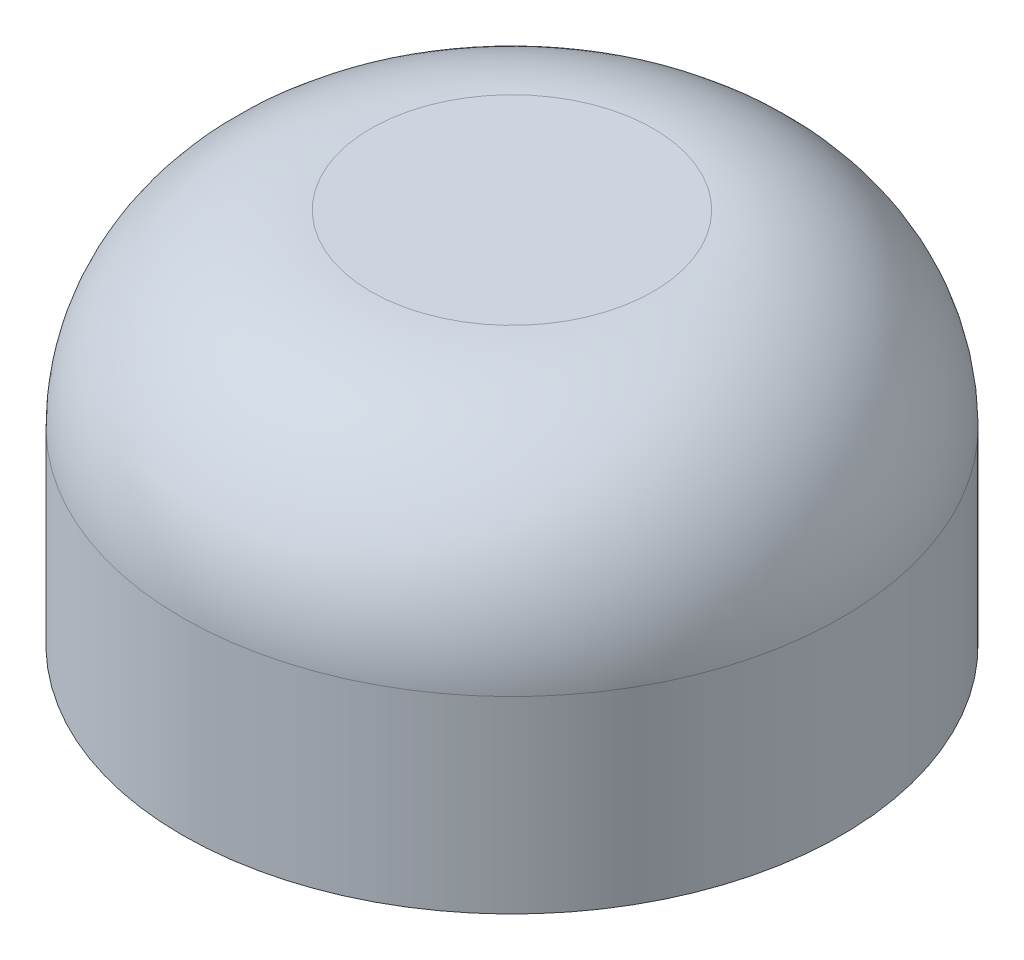
from build123d import *

# Parameters (mm, degrees)
SKETCH1_R           = 1.75
BOSS_EXTRUDE1_DEPTH = 2
FILLET1_R           = 1


with BuildPart() as part:
    # Sketch1 → Boss-Extrude1 (new body)
    with BuildSketch(Plane(origin=(0, 0, 0), x_dir=(1, 0, 0), z_dir=(0, 1, 0))):
        Circle(SKETCH1_R)
    extrude(amount=BOSS_EXTRUDE1_DEPTH)

    # Fillet1
    fillet1_edges = [part.edges().sort_by_distance(p)[0] for p in [
        (-1.75, 2, 0),
    ]]
    fillet(fillet1_edges, radius=FILLET1_R)


solid = part.part
